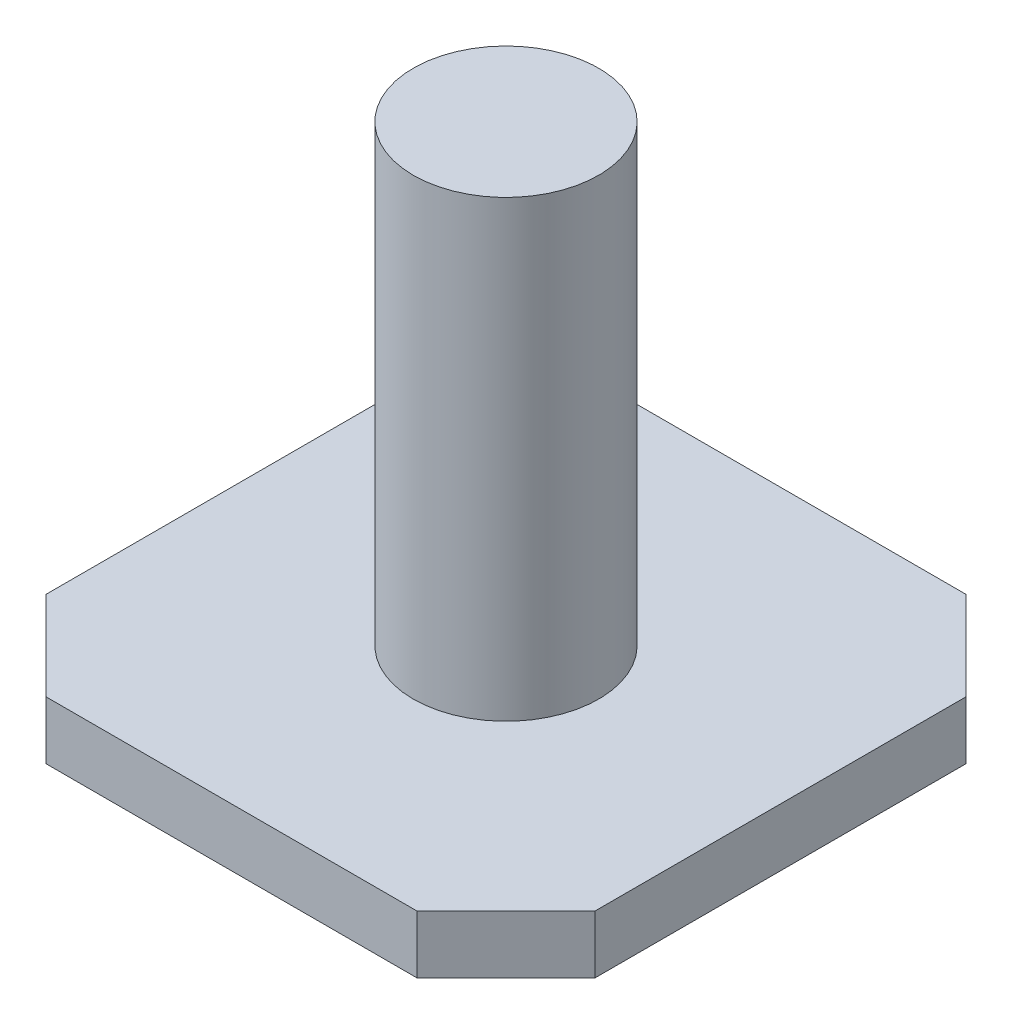
from build123d import *

# Parameters (mm, degrees)
BOSS_EXTRUDE1_DEPTH = 1.905
SKETCH2_R           = 3.048
BOSS_EXTRUDE2_DEPTH = 14.9098


with BuildPart() as part:
    # Sketch1 → Boss-Extrude1 (new body)
    with BuildSketch(Plane(origin=(0, 0, 0), x_dir=(1, 0, 0), z_dir=(0, 1, 0))):
        Polygon((-6.096, 9.017), (6.096, 9.017), (9.017, 6.096), (9.017, -6.096), (6.096, -9.017), (-6.096, -9.017), (-9.017, -6.096), (-9.017, 6.096), align=None)
    extrude(amount=BOSS_EXTRUDE1_DEPTH)

    # Sketch2 → Boss-Extrude2 (add)
    with BuildSketch(Plane(origin=(0, 1.905, 0), x_dir=(1, 0, 0), z_dir=(0, 1, 0))):
        Circle(SKETCH2_R)
    extrude(amount=BOSS_EXTRUDE2_DEPTH)


solid = part.part
